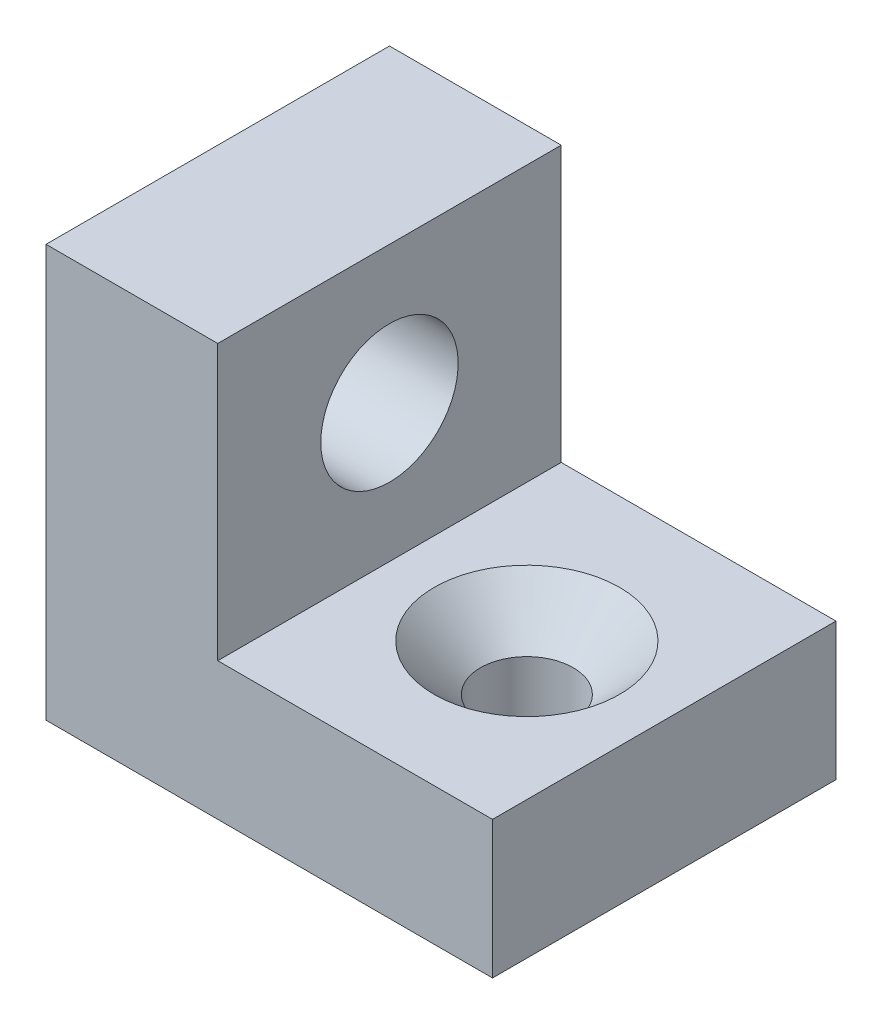
from build123d import *

# Parameters (mm, degrees)
SKETCH1_W                                       = 40
SKETCH1_H                                       = 50
BOSS_EXTRUDE1_DEPTH                             = 20
CSK_FOR_M2_FLAT_HEAD_MACHINE_SCREW1_D           = 13.5
CSK_FOR_M2_FLAT_HEAD_MACHINE_SCREW1_CSINK_D     = 27
CSK_FOR_M2_FLAT_HEAD_MACHINE_SCREW1_CSINK_ANGLE = 90
SKETCH4_W                                       = 50
SKETCH4_H                                       = 60
SKETCH4_R                                       = 10
BOSS_EXTRUDE2_DEPTH                             = 25


with BuildPart() as part:
    # Sketch1 → Boss-Extrude1 (new body)
    with BuildSketch(Plane(origin=(0, 0, 0), x_dir=(1, 0, 0), z_dir=(0, 1, 0))):
        with Locations((20, -25)):
            Rectangle(SKETCH1_W, SKETCH1_H)
    extrude(amount=BOSS_EXTRUDE1_DEPTH)

    # CSK for M2 Flat Head Machine Screw1 (through all)
    with Locations(Plane(origin=(0, 20, 0), x_dir=(1, 0, 0), z_dir=(0, 1, 0))):
        with Locations((20, -25)):
            CounterSinkHole(CSK_FOR_M2_FLAT_HEAD_MACHINE_SCREW1_D / 2, CSK_FOR_M2_FLAT_HEAD_MACHINE_SCREW1_CSINK_D / 2, counter_sink_angle=CSK_FOR_M2_FLAT_HEAD_MACHINE_SCREW1_CSINK_ANGLE)

    # Sketch4 → Boss-Extrude2 (add)
    with BuildSketch(Plane.ZY):
        with Locations((25, 30)):
            Rectangle(SKETCH4_W, SKETCH4_H)
        with Locations((25, 40)):
            Circle(SKETCH4_R, mode=Mode.SUBTRACT)
    extrude(amount=BOSS_EXTRUDE2_DEPTH)


solid = part.part
